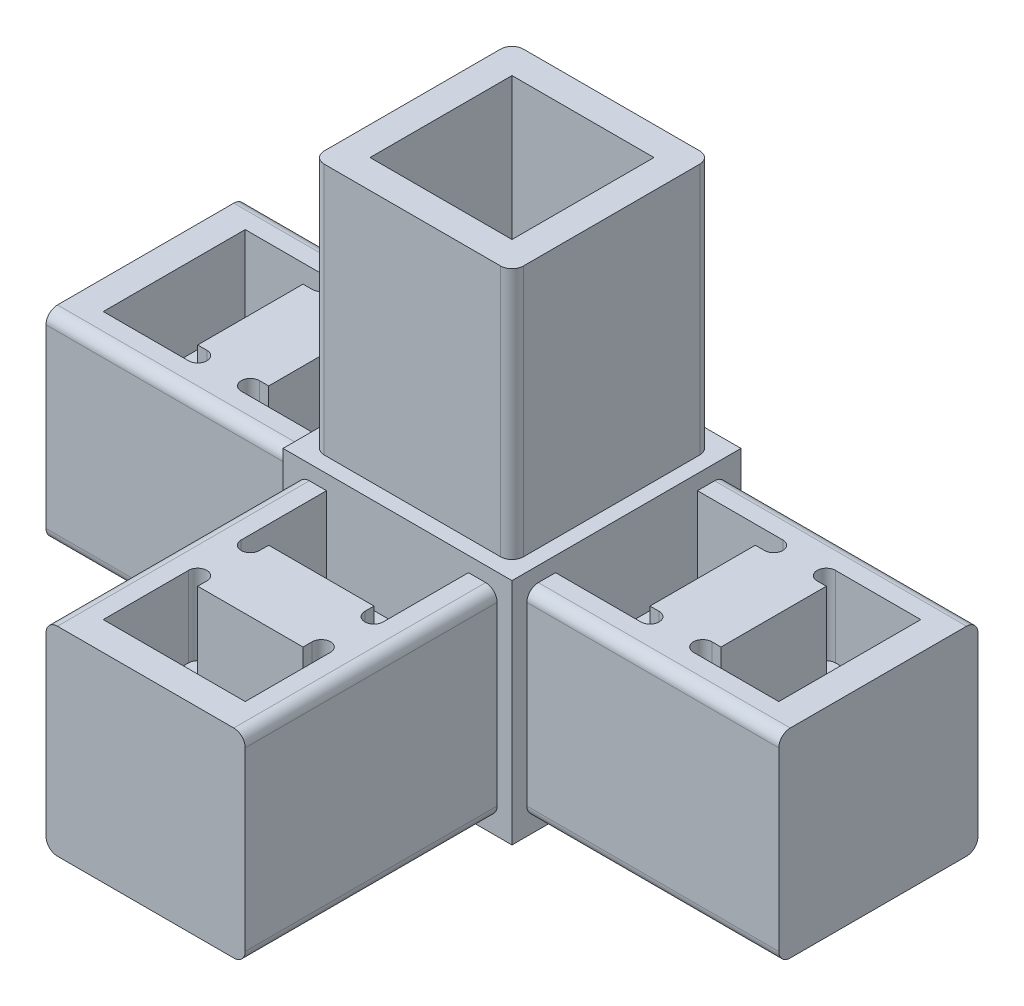
from build123d import *

# Parameters (mm, degrees)
SKETCH1_W           = 81.28
SKETCH1_H           = 53.34
BOSS_EXTRUDE1_DEPTH = 22.098
SKETCH2_W           = 27.94
SKETCH2_H           = 22.098
CUT_EXTRUDE1_DEPTH  = 29.591
SKETCH3_W           = 27.94
SKETCH3_H           = 22.098
CUT_EXTRUDE2_DEPTH  = 1.651
SKETCH4_W           = 27.94
SKETCH4_H           = 22.098
CUT_EXTRUDE3_DEPTH  = 29.591
SKETCH5_W           = 27.94
SKETCH5_H           = 22.098
CUT_EXTRUDE4_DEPTH  = 1.651
SKETCH6_W           = 27.94
SKETCH6_H           = 22.098
CUT_EXTRUDE5_DEPTH  = 1.651
CUT_EXTRUDE6_DEPTH  = 8.89
SKETCH8_W           = 27.94
SKETCH8_H           = 22.098
CUT_EXTRUDE7_DEPTH  = 1.651
CUT_EXTRUDE8_DEPTH  = 8.89
SKETCH10_W          = 25.4
SKETCH10_H          = 25.4
BOSS_EXTRUDE2_DEPTH = 1.651
SKETCH11_W          = 25.4
SKETCH11_H          = 25.4
BOSS_EXTRUDE3_DEPTH = 1.651
CUT_EXTRUDE9_DEPTH  = 8.89
CUT_EXTRUDE10_DEPTH = 8.89
CUT_EXTRUDE11_DEPTH = 8.89
CUT_EXTRUDE12_DEPTH = 8.89
CUT_EXTRUDE13_DEPTH = 8.89
CUT_EXTRUDE14_DEPTH = 8.89
CUT_EXTRUDE15_DEPTH = 8.89
CUT_EXTRUDE16_DEPTH = 8.89
CUT_EXTRUDE17_DEPTH = 8.89
CUT_EXTRUDE18_DEPTH = 8.89
SKETCH22_W          = 22.098
SKETCH22_H          = 22.098
BOSS_EXTRUDE4_DEPTH = 27.94
SKETCH23_W          = 15.748
SKETCH23_H          = 15.748
CUT_EXTRUDE19_DEPTH = 27.94
FILLET1_R           = 1.27


with BuildPart() as part:
    # Sketch1 → Boss-Extrude1 (new body)
    with BuildSketch(Plane.XZ.offset(11.049)):
        with Locations((0, 13.97)):
            Rectangle(SKETCH1_W, SKETCH1_H)
    extrude(amount=-BOSS_EXTRUDE1_DEPTH)

    # Sketch2 → Cut-Extrude1 (cut)
    with BuildSketch(Plane.XY.offset(40.64)):
        with Locations((-26.67, 0)):
            Rectangle(SKETCH2_W, SKETCH2_H)
    extrude(amount=-CUT_EXTRUDE1_DEPTH, mode=Mode.SUBTRACT)

    # Sketch3 → Cut-Extrude2 (cut)
    with BuildSketch(Plane(origin=(0, 0, -12.7), x_dir=(-1, 0, 0), z_dir=(0, 0, -1))):
        with Locations((26.67, 0)):
            Rectangle(SKETCH3_W, SKETCH3_H)
    extrude(amount=-CUT_EXTRUDE2_DEPTH, mode=Mode.SUBTRACT)

    # Sketch4 → Cut-Extrude3 (cut)
    with BuildSketch(Plane(origin=(40.64, 0, 0), x_dir=(0, 0, -1), z_dir=(1, 0, 0))):
        with Locations((-26.67, 0)):
            Rectangle(SKETCH4_W, SKETCH4_H)
    extrude(amount=-CUT_EXTRUDE3_DEPTH, mode=Mode.SUBTRACT)

    # Sketch5 → Cut-Extrude4 (cut)
    with BuildSketch(Plane.ZY.offset(12.7)):
        with Locations((26.67, 0)):
            Rectangle(SKETCH5_W, SKETCH5_H)
    extrude(amount=-CUT_EXTRUDE4_DEPTH, mode=Mode.SUBTRACT)

    # Sketch6 → Cut-Extrude5 (cut)
    with BuildSketch(Plane.XY.offset(12.7)):
        with Locations((26.67, 0)):
            Rectangle(SKETCH6_W, SKETCH6_H)
    extrude(amount=-CUT_EXTRUDE5_DEPTH, mode=Mode.SUBTRACT)

    # Sketch7 → Cut-Extrude6 (cut)
    with BuildSketch(Plane(origin=(0, 11.049, 0), x_dir=(-1, 0, 0), z_dir=(0, 1, 0))):
        with BuildLine():
            Line((-12.7, -7.874), (-12.7, 7.874))
            Line((-12.7, 7.874), (-22.1615, 7.874))
            ThreePointArc((-22.1615, 7.874), (-23.1775, 6.858), (-22.1615, 5.842))
            Line((-22.1615, 5.842), (-21.1455, 5.842))
            Line((-21.1455, 5.842), (-21.1455, -5.842))
            Line((-21.1455, -5.842), (-22.1615, -5.842))
            ThreePointArc((-22.1615, -5.842), (-23.1775, -6.858), (-22.1615, -7.874))
            Line((-22.1615, -7.874), (-12.7, -7.874))
        make_face()
    extrude(amount=-CUT_EXTRUDE6_DEPTH, mode=Mode.SUBTRACT)

    # Sketch8 → Cut-Extrude7 (cut)
    with BuildSketch(Plane(origin=(0, 0, -12.7), x_dir=(-1, 0, 0), z_dir=(0, 0, -1))):
        with Locations((-26.67, 0)):
            Rectangle(SKETCH8_W, SKETCH8_H)
    extrude(amount=-CUT_EXTRUDE7_DEPTH, mode=Mode.SUBTRACT)

    # Sketch9 → Cut-Extrude8 (cut)
    with BuildSketch(Plane(origin=(0, 11.049, 0), x_dir=(-1, 0, 0), z_dir=(0, 1, 0))):
        with BuildLine():
            Line((7.874, 12.7), (7.874, 22.1615))
            ThreePointArc((7.874, 22.1615), (6.858, 23.1775), (5.842, 22.1615))
            Line((5.842, 22.1615), (5.842, 21.1455))
            Line((5.842, 21.1455), (-5.842, 21.1455))
            Line((-5.842, 21.1455), (-5.842, 22.1615))
            ThreePointArc((-5.842, 22.1615), (-6.858, 23.1775), (-7.874, 22.1615))
            Line((-7.874, 22.1615), (-7.874, 12.7))
            Line((-7.874, 12.7), (7.874, 12.7))
        make_face()
    extrude(amount=-CUT_EXTRUDE8_DEPTH, mode=Mode.SUBTRACT)

    # Sketch10 → Boss-Extrude2 (add)
    with BuildSketch(Plane(origin=(0, 11.049, 0), x_dir=(-1, 0, 0), z_dir=(0, 1, 0))):
        Rectangle(SKETCH10_W, SKETCH10_H)
    extrude(amount=BOSS_EXTRUDE2_DEPTH)

    # Sketch11 → Boss-Extrude3 (add)
    with BuildSketch(Plane.XZ.offset(11.049)):
        Rectangle(SKETCH11_W, SKETCH11_H)
    extrude(amount=BOSS_EXTRUDE3_DEPTH)

    # Sketch12 → Cut-Extrude9 (cut)
    with BuildSketch(Plane.XZ.offset(11.049)):
        with BuildLine():
            Line((-7.874, 22.1615), (-7.874, 12.7))
            Line((-7.874, 12.7), (7.874, 12.7))
            Line((7.874, 12.7), (7.874, 22.1615))
            ThreePointArc((7.874, 22.1615), (6.858, 23.1775), (5.842, 22.1615))
            Line((5.842, 22.1615), (5.842, 21.1455))
            Line((5.842, 21.1455), (-5.842, 21.1455))
            Line((-5.842, 21.1455), (-5.842, 22.1615))
            ThreePointArc((-5.842, 22.1615), (-6.858, 23.1775), (-7.874, 22.1615))
        make_face()
    extrude(amount=-CUT_EXTRUDE9_DEPTH, mode=Mode.SUBTRACT)

    # Sketch13 → Cut-Extrude10 (cut)
    with BuildSketch(Plane.XZ.offset(11.049)):
        with BuildLine():
            Line((12.7, 7.874), (12.7, -7.874))
            Line((12.7, -7.874), (22.1615, -7.874))
            ThreePointArc((22.1615, -7.874), (23.1775, -6.858), (22.1615, -5.842))
            Line((22.1615, -5.842), (21.1455, -5.842))
            Line((21.1455, -5.842), (21.1455, 5.842))
            Line((21.1455, 5.842), (22.1615, 5.842))
            ThreePointArc((22.1615, 5.842), (23.1775, 6.858), (22.1615, 7.874))
            Line((22.1615, 7.874), (12.7, 7.874))
        make_face()
    extrude(amount=-CUT_EXTRUDE10_DEPTH, mode=Mode.SUBTRACT)

    # Sketch14 → Cut-Extrude11 (cut)
    with BuildSketch(Plane.XZ.offset(11.049)):
        with BuildLine():
            Line((-22.1615, 5.842), (-21.1455, 5.842))
            Line((-21.1455, 5.842), (-21.1455, -5.842))
            Line((-21.1455, -5.842), (-22.1615, -5.842))
            ThreePointArc((-22.1615, -5.842), (-23.1775, -6.858), (-22.1615, -7.874))
            Line((-22.1615, -7.874), (-12.7, -7.874))
            Line((-12.7, -7.874), (-12.7, 7.874))
            Line((-12.7, 7.874), (-22.1615, 7.874))
            ThreePointArc((-22.1615, 7.874), (-23.1775, 6.858), (-22.1615, 5.842))
        make_face()
    extrude(amount=-CUT_EXTRUDE11_DEPTH, mode=Mode.SUBTRACT)

    # Sketch15 → Cut-Extrude12 (cut)
    with BuildSketch(Plane(origin=(0, 11.049, 0), x_dir=(-1, 0, 0), z_dir=(0, 1, 0))):
        with BuildLine():
            Line((21.1455, 5.842), (22.1615, 5.842))
            ThreePointArc((22.1615, 5.842), (23.1775, 6.858), (22.1615, 7.874))
            Line((22.1615, 7.874), (12.7, 7.874))
            Line((12.7, 7.874), (12.7, -7.874))
            Line((12.7, -7.874), (22.1615, -7.874))
            ThreePointArc((22.1615, -7.874), (23.1775, -6.858), (22.1615, -5.842))
            Line((22.1615, -5.842), (21.1455, -5.842))
            Line((21.1455, -5.842), (21.1455, 5.842))
        make_face()
    extrude(amount=-CUT_EXTRUDE12_DEPTH, mode=Mode.SUBTRACT)

    # Sketch16 → Cut-Extrude13 (cut)
    with BuildSketch(Plane.XZ.offset(11.049)):
        with BuildLine():
            Line((-37.465, 7.874), (-37.465, -7.874))
            Line((-37.465, -7.874), (-28.0035, -7.874))
            ThreePointArc((-28.0035, -7.874), (-26.9875, -6.858), (-28.0035, -5.842))
            Line((-28.0035, -5.842), (-29.0195, -5.842))
            Line((-29.0195, -5.842), (-29.0195, 5.842))
            Line((-29.0195, 5.842), (-28.0035, 5.842))
            ThreePointArc((-28.0035, 5.842), (-26.9875, 6.858), (-28.0035, 7.874))
            Line((-28.0035, 7.874), (-37.465, 7.874))
        make_face()
    extrude(amount=-CUT_EXTRUDE13_DEPTH, mode=Mode.SUBTRACT)

    # Sketch17 → Cut-Extrude14 (cut)
    with BuildSketch(Plane.XZ.offset(11.049)):
        with BuildLine():
            Line((28.0035, 5.842), (29.0195, 5.842))
            Line((29.0195, 5.842), (29.0195, -5.842))
            Line((29.0195, -5.842), (28.0035, -5.842))
            ThreePointArc((28.0035, -5.842), (26.9875, -6.858), (28.0035, -7.874))
            Line((28.0035, -7.874), (37.465, -7.874))
            Line((37.465, -7.874), (37.465, 7.874))
            Line((37.465, 7.874), (28.0035, 7.874))
            ThreePointArc((28.0035, 7.874), (26.9875, 6.858), (28.0035, 5.842))
        make_face()
    extrude(amount=-CUT_EXTRUDE14_DEPTH, mode=Mode.SUBTRACT)

    # Sketch18 → Cut-Extrude15 (cut)
    with BuildSketch(Plane(origin=(0, 11.049, 0), x_dir=(-1, 0, 0), z_dir=(0, 1, 0))):
        with BuildLine():
            Line((-29.0195, -5.842), (-29.0195, 5.842))
            Line((-29.0195, 5.842), (-28.0035, 5.842))
            ThreePointArc((-28.0035, 5.842), (-26.9875, 6.858), (-28.0035, 7.874))
            Line((-28.0035, 7.874), (-37.465, 7.874))
            Line((-37.465, 7.874), (-37.465, -7.874))
            Line((-37.465, -7.874), (-28.0035, -7.874))
            ThreePointArc((-28.0035, -7.874), (-26.9875, -6.858), (-28.0035, -5.842))
            Line((-28.0035, -5.842), (-29.0195, -5.842))
        make_face()
    extrude(amount=-CUT_EXTRUDE15_DEPTH, mode=Mode.SUBTRACT)

    # Sketch19 → Cut-Extrude16 (cut)
    with BuildSketch(Plane.XZ.offset(11.049)):
        with BuildLine():
            Line((-7.874, 37.465), (-7.874, 28.0035))
            ThreePointArc((-7.874, 28.0035), (-6.858, 26.9875), (-5.842, 28.0035))
            Line((-5.842, 28.0035), (-5.842, 29.0195))
            Line((-5.842, 29.0195), (5.842, 29.0195))
            Line((5.842, 29.0195), (5.842, 28.0035))
            ThreePointArc((5.842, 28.0035), (6.858, 26.9875), (7.874, 28.0035))
            Line((7.874, 28.0035), (7.874, 37.465))
            Line((7.874, 37.465), (-7.874, 37.465))
        make_face()
    extrude(amount=-CUT_EXTRUDE16_DEPTH, mode=Mode.SUBTRACT)

    # Sketch20 → Cut-Extrude17 (cut)
    with BuildSketch(Plane(origin=(0, 11.049, 0), x_dir=(-1, 0, 0), z_dir=(0, 1, 0))):
        with BuildLine():
            Line((5.842, 29.0195), (5.842, 28.0035))
            ThreePointArc((5.842, 28.0035), (6.858, 26.9875), (7.874, 28.0035))
            Line((7.874, 28.0035), (7.874, 37.465))
            Line((7.874, 37.465), (-7.874, 37.465))
            Line((-7.874, 37.465), (-7.874, 28.0035))
            ThreePointArc((-7.874, 28.0035), (-6.858, 26.9875), (-5.842, 28.0035))
            Line((-5.842, 28.0035), (-5.842, 29.0195))
            Line((-5.842, 29.0195), (5.842, 29.0195))
        make_face()
    extrude(amount=-CUT_EXTRUDE17_DEPTH, mode=Mode.SUBTRACT)

    # Sketch21 → Cut-Extrude18 (cut)
    with BuildSketch(Plane(origin=(0, 11.049, 0), x_dir=(-1, 0, 0), z_dir=(0, 1, 0))):
        with BuildLine():
            Line((28.0035, -7.874), (37.465, -7.874))
            Line((37.465, -7.874), (37.465, 7.874))
            Line((37.465, 7.874), (28.0035, 7.874))
            ThreePointArc((28.0035, 7.874), (26.9875, 6.858), (28.0035, 5.842))
            Line((28.0035, 5.842), (29.0195, 5.842))
            Line((29.0195, 5.842), (29.0195, -5.842))
            Line((29.0195, -5.842), (28.0035, -5.842))
            ThreePointArc((28.0035, -5.842), (26.9875, -6.858), (28.0035, -7.874))
        make_face()
    extrude(amount=-CUT_EXTRUDE18_DEPTH, mode=Mode.SUBTRACT)

    # Sketch22 → Boss-Extrude4 (add)
    with BuildSketch(Plane(origin=(0, 12.7, 0), x_dir=(-1, 0, 0), z_dir=(0, 1, 0))):
        Rectangle(SKETCH22_W, SKETCH22_H)
    extrude(amount=BOSS_EXTRUDE4_DEPTH)

    # Sketch23 → Cut-Extrude19 (cut)
    with BuildSketch(Plane(origin=(0, 40.64, 0), x_dir=(-1, 0, 0), z_dir=(0, 1, 0))):
        Rectangle(SKETCH23_W, SKETCH23_H)
    extrude(amount=-CUT_EXTRUDE19_DEPTH, mode=Mode.SUBTRACT)

    # Fillet1
    fillet1_edges = [part.edges().sort_by_distance(p)[0] for p in [
        (26.67, 11.049, -11.049),
        (26.67, -11.049, -11.049),
        (-26.67, 11.049, 11.049),
        (-26.67, -11.049, 11.049),
        (-26.67, -11.049, -11.049),
        (-26.67, 11.049, -11.049),
        (-11.049, 26.67, -11.049),
        (-11.049, 26.67, 11.049),
        (11.049, 26.67, 11.049),
        (11.049, 26.67, -11.049),
        (11.049, -11.049, 26.67),
        (11.049, 11.049, 26.67),
        (-11.049, 11.049, 26.67),
        (-11.049, -11.049, 26.67),
        (26.67, -11.049, 11.049),
        (26.67, 11.049, 11.049),
    ]]
    fillet(fillet1_edges, radius=FILLET1_R)


solid = part.part
